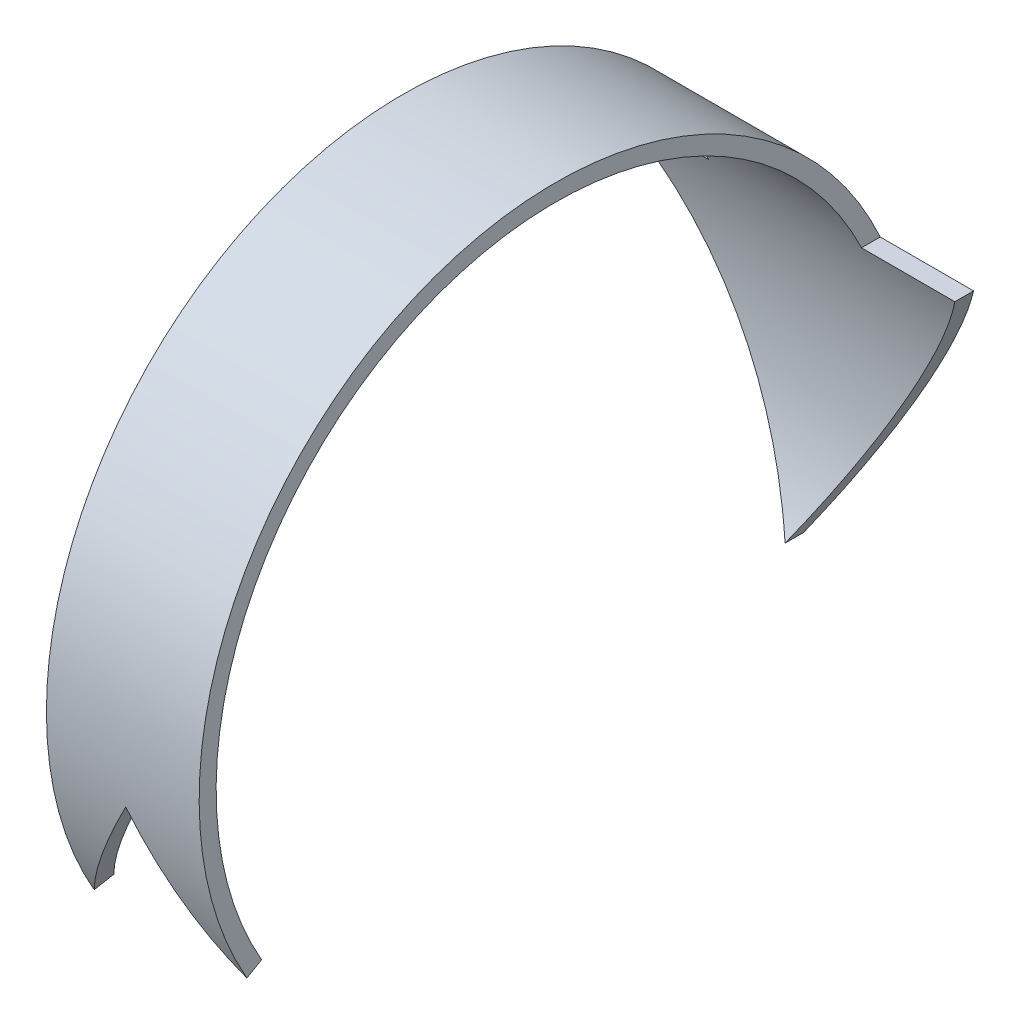
from build123d import *

# Parameters (mm, degrees)
CIRCULARBAND_W               = 15
CIRCULARBAND_H               = 0.75
BASE_REVOLVE_ANGLE           = 120
BASE_REVOLVE_OTHER_WAY_ANGLE = 120
SKETCH9_OUTSIDE_W            = 25.428
SKETCH9_OUTSIDE_H            = 34.053
HEAD1_DEPTH                  = 16.75
SKETCH10_OUTSIDE_W           = 25.428
SKETCH10_OUTSIDE_H           = 34.053
TAIL1_DEPTH                  = 16.75


with BuildPart() as part:
    # circularband → Base-Revolve (revolve)
    with BuildSketch(Plane.XY):
        with Locations((0, 15.375)):
            Rectangle(CIRCULARBAND_W, CIRCULARBAND_H)
    revolve(axis=Axis((0, 0, 0), (1, 0, 0)), revolution_arc=BASE_REVOLVE_ANGLE)

    # circularband → Base-Revolve other way (revolve)
    with BuildSketch(Plane.XY):
        with Locations((0, 15.375)):
            Rectangle(CIRCULARBAND_W, CIRCULARBAND_H)
    revolve(axis=Axis((0, 0, 0), (-1, 0, 0)), revolution_arc=BASE_REVOLVE_OTHER_WAY_ANGLE)

    # Sketch9 outside → head1 (cut, through all)
    with BuildSketch(Plane.XY):
        with Locations((0, 3.9375)):
            Rectangle(SKETCH9_OUTSIDE_W, SKETCH9_OUTSIDE_H)
        Polygon((-3.375, 15.75), (3.375, 15.75), (3.375, 6.490381057), (7.5, 6.490381057), (0, -6.5), (-7.5, 6.490381057), (-3.375, 6.490381057), align=None, mode=Mode.SUBTRACT)
    extrude(amount=-HEAD1_DEPTH, mode=Mode.SUBTRACT)

    # Sketch10 outside → tail1 (cut, through all)
    with BuildSketch(Plane.XY):
        with Locations((0, 3.9375)):
            Rectangle(SKETCH10_OUTSIDE_W, SKETCH10_OUTSIDE_H)
        Polygon((0, -2.029328524), (3.375, -7.875), (3.375, 15.75), (-3.375, 15.75), (-3.375, -7.875), align=None, mode=Mode.SUBTRACT)
    extrude(amount=TAIL1_DEPTH, mode=Mode.SUBTRACT)


solid = part.part
